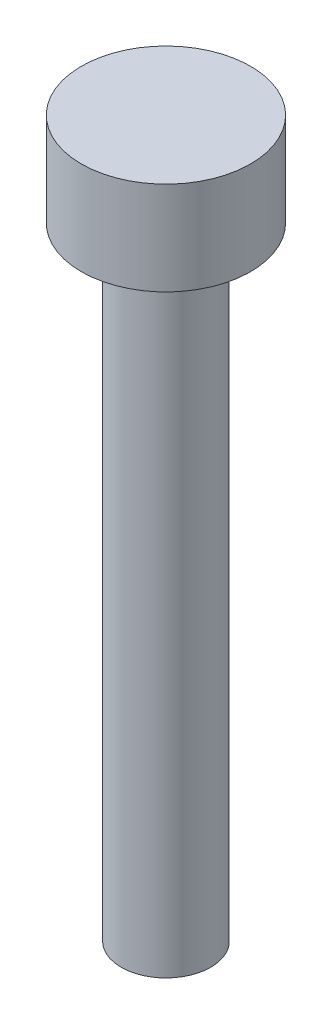
from build123d import *

# Parameters (mm, degrees)
SKETCH1_R           = 2.72
BOSS_EXTRUDE1_DEPTH = 3
SKETCH2_R           = 1.44
BOSS_EXTRUDE2_DEPTH = 20


with BuildPart() as part:
    # Sketch1 → Boss-Extrude1 (new body)
    with BuildSketch(Plane(origin=(0, 0, 0), x_dir=(1, 0, 0), z_dir=(0, 1, 0))):
        Circle(SKETCH1_R)
    extrude(amount=BOSS_EXTRUDE1_DEPTH)

    # Sketch2 → Boss-Extrude2 (add)
    with BuildSketch(Plane.XZ):
        Circle(SKETCH2_R)
    extrude(amount=BOSS_EXTRUDE2_DEPTH)


solid = part.part
